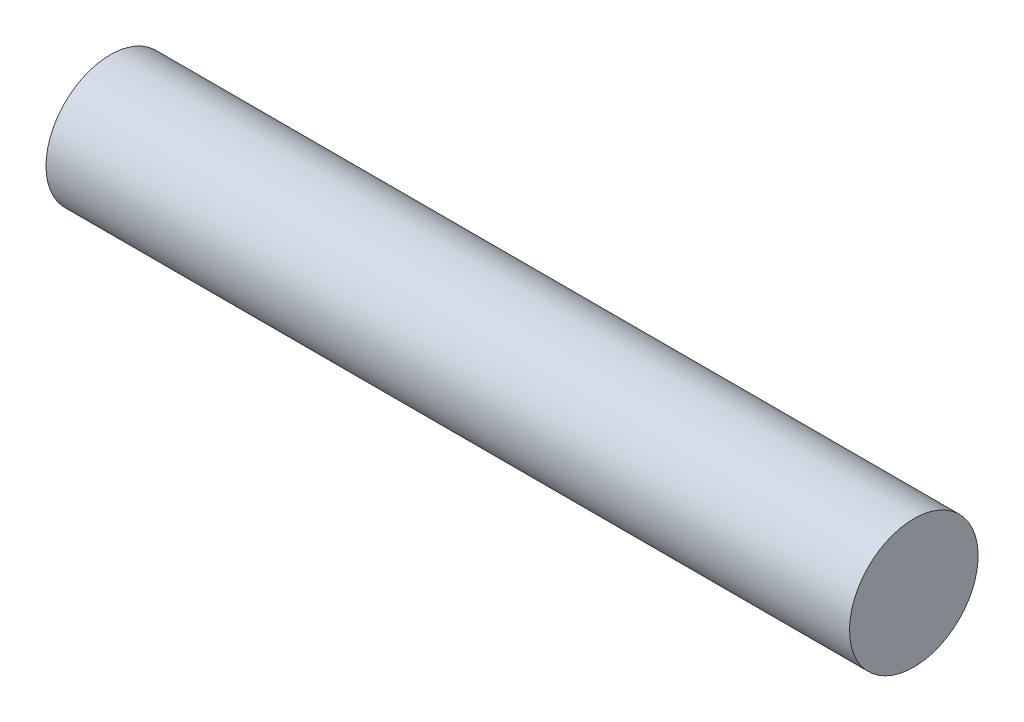
from build123d import *


with BuildPart() as part:
    # Esquisse1 → Révolution1 (revolve)
    with BuildSketch(Plane.XY):
        Polygon((0, 4), (0, 3), (20, 3), (20, 0), (50, 0), (50, 4), align=None)
    revolve(axis=Axis((20, 0, 0), (1, 0, 0)))


solid = part.part
